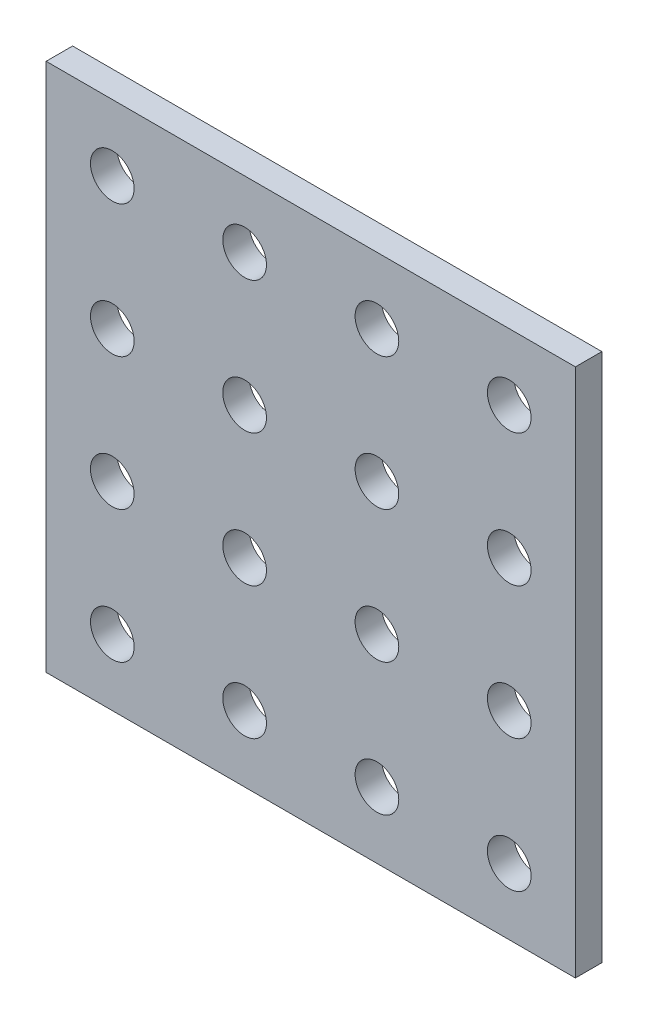
from build123d import *

# Parameters (mm, degrees)
SKETCH1_W            = 40
SKETCH1_H            = 40
BOSS_EXTRUDE1_DEPTH  = 2
SKETCH2_R            = 1.65
CUT_EXTRUDE1_DEPTH   = 3
LPATTERN1_COUNT      = 4
LPATTERN1_PITCH      = 10
LPATTERN1_COUNT_DIR2 = 4
LPATTERN1_PITCH_DIR2 = 10


with BuildPart() as part:
    # Sketch1 → Boss-Extrude1 (new body)
    with BuildSketch(Plane.XY):
        Rectangle(SKETCH1_W, SKETCH1_H)
    extrude(amount=BOSS_EXTRUDE1_DEPTH)

    # Sketch2 → Cut-Extrude1 (cut, through all)
    with BuildSketch(Plane.XY.offset(2)):
        with Locations((-15, 15)):
            Circle(SKETCH2_R)
    cut_extrude1 = extrude(amount=-CUT_EXTRUDE1_DEPTH, mode=Mode.SUBTRACT)

    # LPattern1: Cut-Extrude1 4 × 4
    with Locations(*[(j * LPATTERN1_PITCH_DIR2, -i * LPATTERN1_PITCH, 0) for i in range(LPATTERN1_COUNT) for j in range(LPATTERN1_COUNT_DIR2) if (i, j) != (0, 0)]):
        add(cut_extrude1, mode=Mode.SUBTRACT)


solid = part.part
